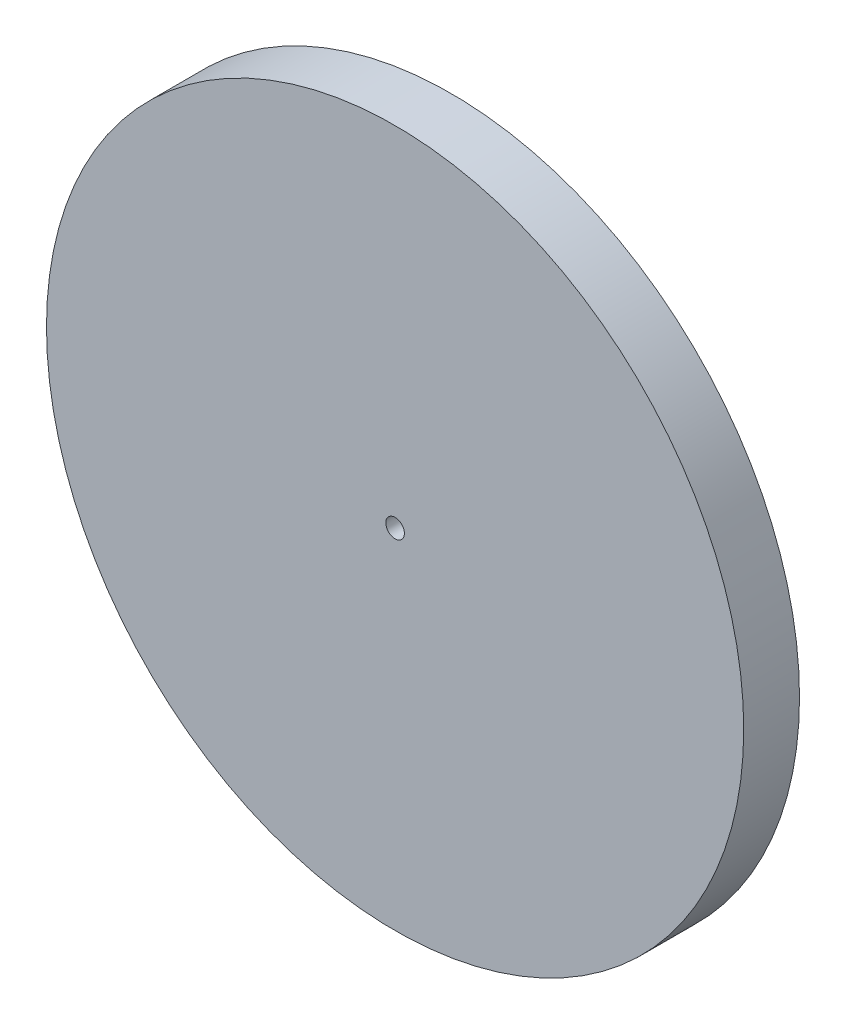
from build123d import *

# Parameters (mm, degrees)
SKETCH1_R           = 37.5
SKETCH1_R_2         = 1
BOSS_EXTRUDE1_DEPTH = 6


with BuildPart() as part:
    # Sketch1 → Boss-Extrude1 (new body)
    with BuildSketch(Plane.XY):
        Circle(SKETCH1_R)
        Circle(SKETCH1_R_2, mode=Mode.SUBTRACT)
    extrude(amount=BOSS_EXTRUDE1_DEPTH)


solid = part.part
